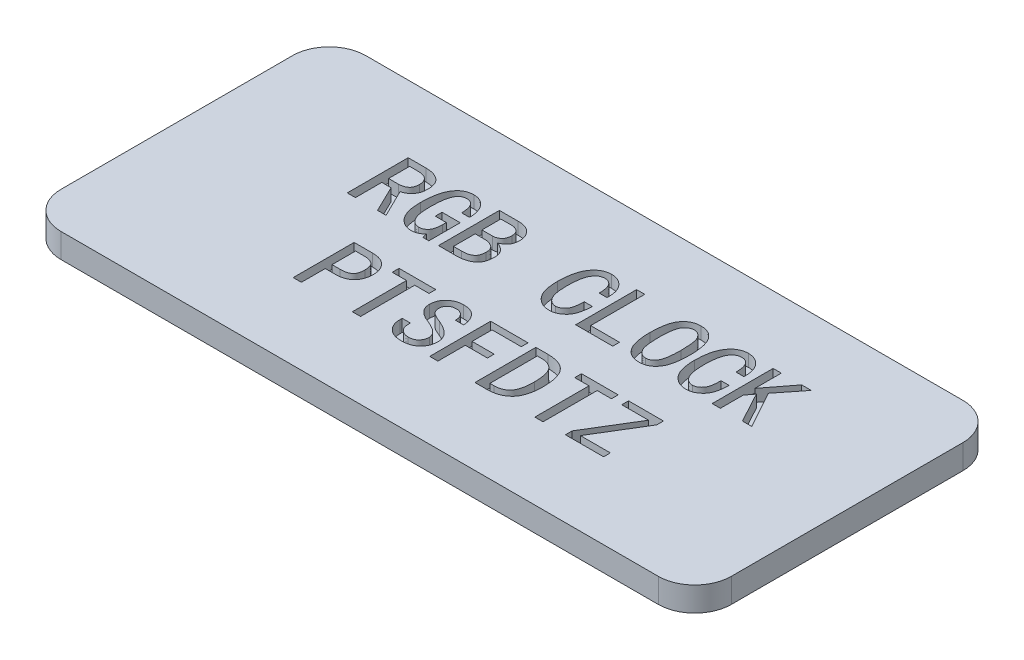
from build123d import *

# Parameters (mm, degrees)
EXTRUDE_1_DEPTH     = 4
CUT_EXTRUDE_1_DEPTH = 2
SKETCH_3_R          = 1.55
CUT_EXTRUDE_2_DEPTH = 2


with BuildPart() as part:
    # 草图1 → 凸台-拉伸1 (new body)
    with BuildSketch(Plane(origin=(0, 0, 0), x_dir=(1, 0, 0), z_dir=(0, 1, 0))):
        with BuildLine():
            Line((-49.060103211, -24.953020455), (48.939896789, -24.953020455))
            ThreePointArc((48.939896789, -24.953020455), (53.182537476, -23.195661143), (54.939896789, -18.953020455))
            Line((54.939896789, -18.953020455), (54.939896789, 19.046979545))
            ThreePointArc((54.939896789, 19.046979545), (53.182537476, 23.289620232), (48.939896789, 25.046979545))
            Line((48.939896789, 25.046979545), (-49.060103211, 25.046979545))
            ThreePointArc((-49.060103211, 25.046979545), (-53.302743898, 23.289620232), (-55.060103211, 19.046979545))
            Line((-55.060103211, 19.046979545), (-55.060103211, -18.953020455))
            ThreePointArc((-55.060103211, -18.953020455), (-53.302743898, -23.195661143), (-49.060103211, -24.953020455))
        make_face()
    extrude(amount=EXTRUDE_1_DEPTH)

    # 草图2 → 切除-拉伸1 (cut)
    with BuildSketch(Plane(origin=(0, 4, 0), x_dir=(1, 0, 0), z_dir=(0, 1, 0))):
        with BuildLine():
            Line((-24.689103402, 4.013286342), (-26.092612174, 4.013286342))
            Line((-26.092612174, 4.013286342), (-28.197875332, 8.340771722))
            Line((-28.197875332, 8.340771722), (-29.718343168, 8.340771722))
            Line((-29.718343168, 8.340771722), (-29.718343168, 4.013286342))
            Line((-29.718343168, 4.013286342), (-31.063372408, 4.013286342))
            Line((-31.063372408, 4.013286342), (-31.063372408, 14.013286342))
            Line((-31.063372408, 14.013286342), (-28.139395799, 14.013286342))
            add(Edge.make_bspline(
                [(-28.139395799, 14.013286342), (-28.025271199, 14.011022447), (-27.801665177, 14.006586764), (-27.474158532, 13.977305773), (-27.163811789, 13.922480888), (-26.869993583, 13.848543864), (-26.591122472, 13.757128365), (-26.330664058, 13.638152685), (-26.084604122, 13.502366925), (-25.856059717, 13.34436888), (-25.649198765, 13.162867164), (-25.468095095, 12.953694485), (-25.317506234, 12.71659107), (-25.19224016, 12.453536513), (-25.098862257, 12.163974849), (-25.028759565, 11.848745919), (-24.988061601, 11.506955486), (-24.983731739, 11.269910871), (-24.981501063, 11.147789266)],
                knots=[0, 0, 0, 0, 0.000342385, 0.00067084, 0.000985262, 0.001286791, 0.001579252, 0.001864265, 0.00214448, 0.002421463, 0.002696123, 0.002967934, 0.003248509, 0.003536249, 0.00383967, 0.004159169, 0.004503848, 0.004870117, 0.004870117, 0.004870117, 0.004870117], degree=3))
            add(Edge.make_bspline(
                [(-24.981501063, 11.147789266), (-24.982879235, 11.053132412), (-24.985568475, 10.868427619), (-25.014691702, 10.599897587), (-25.059459648, 10.347780009), (-25.122091088, 10.111878008), (-25.20381367, 9.892229091), (-25.306953951, 9.68976788), (-25.425462329, 9.502309698), (-25.607220143, 9.280192442), (-25.858260009, 9.03978442), (-26.186011564, 8.801825154), (-26.537419989, 8.621484855), (-26.787121493, 8.551180459), (-26.911325624, 8.516210319)],
                knots=[0, 0, 0, 0, 0.000283866, 0.000553911, 0.00080924, 0.001051445, 0.001285172, 0.001510863, 0.001731967, 0.001949131, 0.002370371, 0.002770706, 0.003161063, 0.003547397, 0.003547397, 0.003547397, 0.003547397], degree=3))
            Line((-26.911325624, 8.516210319), (-24.689103402, 4.013286342))
        make_face()
        with BuildLine():
            add(Edge.make_bspline(
                [(-26.326530302, 11.147789266), (-26.328534479, 11.214250313), (-26.332444587, 11.343914494), (-26.352988156, 11.533501173), (-26.392896046, 11.711592998), (-26.445391927, 11.879642896), (-26.519630989, 12.033952382), (-26.602039127, 12.180903159), (-26.706758189, 12.313205167), (-26.822926271, 12.438010916), (-26.958258394, 12.548784835), (-27.112075487, 12.645663856), (-27.28592479, 12.724656185), (-27.478483614, 12.789349783), (-27.689174032, 12.841491619), (-27.91960733, 12.87741334), (-28.169289215, 12.899287418), (-28.342221339, 12.901189847), (-28.43179346, 12.902175231)],
                knots=[0, 0, 0, 0, 0.000199452, 0.000389127, 0.00057096, 0.000746305, 0.000915883, 0.001083793, 0.001250582, 0.001420644, 0.001594525, 0.001773602, 0.00196451, 0.002165881, 0.002382309, 0.00261483, 0.002864849, 0.0031335, 0.0031335, 0.0031335, 0.0031335], degree=3))
            Line((-28.43179346, 12.902175231), (-29.718343168, 12.902175231))
            Line((-29.718343168, 12.902175231), (-29.718343168, 9.451882834))
            Line((-29.718343168, 9.451882834), (-28.080916267, 9.451882834))
            add(Edge.make_bspline(
                [(-28.080916267, 9.451882834), (-27.967162713, 9.456192603), (-27.744517212, 9.464627952), (-27.422963771, 9.538637856), (-27.122727476, 9.656901993), (-26.892686197, 9.794736061), (-26.726225717, 9.931497522), (-26.619535608, 10.055327959), (-26.52747784, 10.194651609), (-26.454418562, 10.352823259), (-26.395491566, 10.526910596), (-26.355058864, 10.718817973), (-26.33161966, 10.927724938), (-26.328268216, 11.072641731), (-26.326530302, 11.147789266)],
                knots=[0, 0, 0, 0, 0.000340881, 0.000667194, 0.000984128, 0.001305807, 0.001467207, 0.001628375, 0.001794177, 0.001966635, 0.00214951, 0.002344502, 0.00255379, 0.002779211, 0.002779211, 0.002779211, 0.002779211], degree=3))
        make_face(mode=Mode.SUBTRACT)
        with BuildLine():
            Line((-17.554600478, 3.896327278), (-18.548752525, 3.896327278))
            Line((-18.548752525, 3.896327278), (-18.724191121, 4.715040728))
            add(Edge.make_bspline(
                [(-18.724191121, 4.715040728), (-18.767152967, 4.657138884), (-18.854665698, 4.539193568), (-19.026038271, 4.386135142), (-19.226536717, 4.24628958), (-19.457565649, 4.124634124), (-19.708424871, 4.023547891), (-19.97477921, 3.949068451), (-20.252606224, 3.905489663), (-20.441606207, 3.899401816), (-20.537056618, 3.896327278)],
                knots=[0, 0, 0, 0, 0.00021581, 0.000439602, 0.000685354, 0.000947938, 0.001221032, 0.001495342, 0.001775942, 0.002062244, 0.002062244, 0.002062244, 0.002062244], degree=3))
            add(Edge.make_bspline(
                [(-20.537056618, 3.896327278), (-20.638393329, 3.899391095), (-20.839657805, 3.90547613), (-21.13618719, 3.962600689), (-21.425231964, 4.051279527), (-21.704153682, 4.178397868), (-21.976875627, 4.337911454), (-22.238279392, 4.537458024), (-22.493912412, 4.769441759), (-22.740767076, 5.036015722), (-22.966273141, 5.344424008), (-23.164784586, 5.695546473), (-23.32799682, 6.092111115), (-23.464059213, 6.529062097), (-23.566434359, 7.010010435), (-23.641434184, 7.532375234), (-23.686945452, 8.098107577), (-23.692223493, 8.489410749), (-23.694951355, 8.691648915)],
                knots=[0, 0, 0, 0, 0.000303722, 0.000603221, 0.000902595, 0.001208939, 0.001520596, 0.001848515, 0.002193521, 0.002555286, 0.00293651, 0.003337069, 0.003762255, 0.004220553, 0.004708263, 0.005235722, 0.005802851, 0.006409495, 0.006409495, 0.006409495, 0.006409495], degree=3))
            add(Edge.make_bspline(
                [(-23.694951355, 8.691648915), (-23.692775035, 8.913359196), (-23.688560111, 9.342750131), (-23.64721628, 9.965234327), (-23.578680878, 10.543660505), (-23.484728573, 11.078660128), (-23.362347657, 11.569958556), (-23.210680663, 12.017543399), (-23.03499896, 12.423166267), (-22.827454191, 12.782962495), (-22.597994066, 13.100142258), (-22.348366649, 13.377015533), (-22.074672425, 13.607010018), (-21.78531097, 13.801514937), (-21.472128306, 13.950116449), (-21.138594106, 14.052909771), (-20.785784046, 14.118253452), (-20.543847628, 14.126187271), (-20.420097554, 14.130245407)],
                knots=[0, 0, 0, 0, 0.000665061, 0.001288037, 0.001870474, 0.002411743, 0.002916567, 0.0033878, 0.003828071, 0.004240448, 0.004631225, 0.005000707, 0.005355685, 0.005701099, 0.006044058, 0.006391368, 0.006745691, 0.007116694, 0.007116694, 0.007116694, 0.007116694], degree=3))
            add(Edge.make_bspline(
                [(-20.420097554, 14.130245407), (-20.31089217, 14.127663594), (-20.097162626, 14.122610641), (-19.786366853, 14.073459764), (-19.493509176, 13.995694028), (-19.219088008, 13.887269168), (-18.962659104, 13.747353038), (-18.72579707, 13.575140885), (-18.507153532, 13.371322521), (-18.309367476, 13.137789323), (-18.133200876, 12.879637721), (-17.975218896, 12.604203803), (-17.846062031, 12.30800801), (-17.74010364, 11.994015887), (-17.654617307, 11.662735271), (-17.59835451, 11.31172633), (-17.559219047, 10.943636818), (-17.5561611, 10.691613794), (-17.554600478, 10.562993945)],
                knots=[0, 0, 0, 0, 0.000327403, 0.000640772, 0.000941296, 0.001234902, 0.001523748, 0.001815319, 0.002111098, 0.002418382, 0.002731392, 0.003047592, 0.003369549, 0.003699002, 0.004040982, 0.004394563, 0.004764604, 0.005150288, 0.005150288, 0.005150288, 0.005150288], degree=3))
            Line((-17.554600478, 10.562993945), (-18.841150185, 10.562993945))
            add(Edge.make_bspline(
                [(-18.841150185, 10.562993945), (-18.842363108, 10.661930975), (-18.844720629, 10.85423176), (-18.863804287, 11.132682661), (-18.897198766, 11.391969265), (-18.93808892, 11.632983599), (-18.997993791, 11.853819189), (-19.065367542, 12.057291794), (-19.150825297, 12.239282085), (-19.246302474, 12.403821723), (-19.353749221, 12.549263379), (-19.474823059, 12.674131444), (-19.60470689, 12.780583427), (-19.745711067, 12.869918008), (-19.899633309, 12.936018558), (-20.064161926, 12.983347825), (-20.238343238, 13.015685969), (-20.358578166, 13.017967121), (-20.420097554, 13.019134295)],
                knots=[0, 0, 0, 0, 0.000296801, 0.000576882, 0.000836665, 0.001080952, 0.001309483, 0.001522504, 0.001723093, 0.001911427, 0.002092498, 0.002264056, 0.002431841, 0.002595306, 0.002763105, 0.002932392, 0.003108298, 0.003292604, 0.003292604, 0.003292604, 0.003292604], degree=3))
            add(Edge.make_bspline(
                [(-20.420097554, 13.019134295), (-20.496165279, 13.016475256), (-20.643973815, 13.01130843), (-20.858556196, 12.963471092), (-21.058133515, 12.888294549), (-21.244108224, 12.782016552), (-21.414089428, 12.644794379), (-21.565250849, 12.473769415), (-21.708667994, 12.278701694), (-21.830654541, 12.046958379), (-21.942976861, 11.783382142), (-22.033227521, 11.47812312), (-22.116843033, 11.134570334), (-22.178593872, 10.747554505), (-22.231981468, 10.321509925), (-22.263135649, 9.853622017), (-22.289623969, 9.345330453), (-22.290821078, 8.992031024), (-22.291442583, 8.80860798)],
                knots=[0, 0, 0, 0, 0.000227925, 0.000442886, 0.000656082, 0.000865627, 0.001082791, 0.001308181, 0.001548636, 0.001807405, 0.002091808, 0.002406946, 0.002761024, 0.003151993, 0.003581832, 0.00404879, 0.004558336, 0.005108515, 0.005108515, 0.005108515, 0.005108515], degree=3))
            add(Edge.make_bspline(
                [(-22.291442583, 8.80860798), (-22.290155165, 8.635285666), (-22.287680366, 8.302108701), (-22.258608598, 7.823795567), (-22.215470736, 7.386770889), (-22.149669982, 6.993019323), (-22.07279778, 6.639037643), (-21.970334675, 6.328439459), (-21.853553436, 6.057481419), (-21.714391982, 5.828599149), (-21.563744754, 5.635958998), (-21.408798862, 5.469021681), (-21.248920538, 5.327437881), (-21.082454741, 5.211380418), (-20.91122122, 5.117991053), (-20.731516153, 5.056470315), (-20.548356839, 5.014666672), (-20.423937094, 5.009850635), (-20.361618022, 5.007438389)],
                knots=[0, 0, 0, 0, 0.00051989, 0.000999383, 0.001437101, 0.001836615, 0.002196528, 0.002522553, 0.002816359, 0.00307972, 0.003323632, 0.003548897, 0.003762225, 0.003962908, 0.004156693, 0.004345078, 0.004531144, 0.004717865, 0.004717865, 0.004717865, 0.004717865], degree=3))
            add(Edge.make_bspline(
                [(-20.361618022, 5.007438389), (-20.300158704, 5.009046757), (-20.179558496, 5.012202821), (-20.003759679, 5.038580972), (-19.837428873, 5.082083371), (-19.680867947, 5.142563078), (-19.534641443, 5.221122415), (-19.399242701, 5.31709912), (-19.275148506, 5.431456974), (-19.159348015, 5.561994511), (-19.055468567, 5.711367649), (-18.965990888, 5.880988719), (-18.890810411, 6.069064205), (-18.830674499, 6.276756235), (-18.783288112, 6.502688278), (-18.749611337, 6.747306991), (-18.726881054, 7.011199123), (-18.725110263, 7.193510252), (-18.724191121, 7.288140143)],
                knots=[0, 0, 0, 0, 0.000184306, 0.000361659, 0.000531873, 0.000699195, 0.000863933, 0.001028599, 0.001195711, 0.001369105, 0.001551158, 0.001740101, 0.001943212, 0.002157725, 0.002387964, 0.002635153, 0.002898121, 0.00318193, 0.00318193, 0.00318193, 0.00318193], degree=3))
            Line((-18.724191121, 7.288140143), (-18.724191121, 7.931414997))
            Line((-18.724191121, 7.931414997), (-20.537056618, 7.931414997))
            Line((-20.537056618, 7.931414997), (-20.537056618, 9.042526108))
            Line((-20.537056618, 9.042526108), (-17.554600478, 9.042526108))
            Line((-17.554600478, 9.042526108), (-17.554600478, 3.896327278))
        make_face()
        with BuildLine():
            add(Edge.make_bspline(
                [(-9.835302232, 6.995742483), (-9.838194545, 6.85989788), (-9.843764271, 6.598301901), (-9.886592254, 6.221845414), (-9.959392997, 5.878528129), (-10.060927464, 5.566871403), (-10.192620119, 5.288245647), (-10.354225391, 5.041581354), (-10.546643994, 4.829109441), (-10.768818301, 4.650863131), (-11.012354988, 4.500979148), (-11.271908085, 4.370041181), (-11.548147256, 4.259756781), (-11.840570881, 4.168605671), (-12.150073724, 4.099813668), (-12.475002148, 4.050625702), (-12.816438977, 4.019585569), (-13.04944295, 4.015418167), (-13.168635566, 4.013286342)],
                knots=[0, 0, 0, 0, 0.000407473, 0.000784671, 0.001134718, 0.001458686, 0.001765795, 0.002056543, 0.002340211, 0.002621988, 0.002908052, 0.003196703, 0.003493124, 0.003799346, 0.004114617, 0.004443301, 0.004784698, 0.005142237, 0.005142237, 0.005142237, 0.005142237], degree=3))
            Line((-13.168635566, 4.013286342), (-16.092612174, 4.013286342))
            Line((-16.092612174, 4.013286342), (-16.092612174, 14.013286342))
            Line((-16.092612174, 14.013286342), (-13.051676501, 14.013286342))
            add(Edge.make_bspline(
                [(-13.051676501, 14.013286342), (-12.93386989, 14.011787269), (-12.70485588, 14.008873096), (-12.372790656, 13.969705744), (-12.061747202, 13.914150165), (-11.775034516, 13.828427511), (-11.51073713, 13.723106537), (-11.269415541, 13.592361509), (-11.052481177, 13.435089961), (-10.856970566, 13.257760495), (-10.687635158, 13.061853055), (-10.536590849, 12.85864962), (-10.410401534, 12.644173901), (-10.305496411, 12.422138397), (-10.228154288, 12.188849476), (-10.168536596, 11.948038315), (-10.133458665, 11.696798894), (-10.129630325, 11.526207356), (-10.127699893, 11.440186927)],
                knots=[0, 0, 0, 0, 0.000353209, 0.000686632, 0.00100183, 0.001299947, 0.001582696, 0.001854083, 0.002120974, 0.002384682, 0.002644058, 0.002896616, 0.003143264, 0.003389387, 0.003631853, 0.003879279, 0.004132903, 0.004390874, 0.004390874, 0.004390874, 0.004390874], degree=3))
            add(Edge.make_bspline(
                [(-10.127699893, 11.440186927), (-10.129721519, 11.355689627), (-10.133650541, 11.191469402), (-10.153593265, 10.953642681), (-10.193768185, 10.73304651), (-10.245549209, 10.528952583), (-10.319435838, 10.343823652), (-10.401599595, 10.173101795), (-10.505561269, 10.022151827), (-10.65921891, 9.847786058), (-10.866689042, 9.663067585), (-11.119538263, 9.472046624), (-11.378852299, 9.321025488), (-11.559776513, 9.251789978), (-11.648167729, 9.217964705)],
                knots=[0, 0, 0, 0, 0.000253559, 0.000492792, 0.000714995, 0.000925668, 0.001123158, 0.00131204, 0.001492864, 0.001670943, 0.002008228, 0.00232402, 0.002620876, 0.002904444, 0.002904444, 0.002904444, 0.002904444], degree=3))
            add(Edge.make_bspline(
                [(-11.648167729, 9.217964705), (-11.532720987, 9.184783362), (-11.301593202, 9.118353335), (-10.977244338, 8.951804406), (-10.668433447, 8.745472829), (-10.432745001, 8.533986822), (-10.259574641, 8.343794331), (-10.146324647, 8.185724437), (-10.048202855, 8.017418993), (-9.970006563, 7.83535827), (-9.909597457, 7.642205313), (-9.866371104, 7.436987839), (-9.840036599, 7.220241436), (-9.836902482, 7.071624708), (-9.835302232, 6.995742483)],
                knots=[0, 0, 0, 0, 0.0003596, 0.000719929, 0.001088172, 0.001471654, 0.001666453, 0.001858817, 0.002053857, 0.002249809, 0.002451889, 0.002660042, 0.002878187, 0.003105772, 0.003105772, 0.003105772, 0.003105772], degree=3))
        make_face()
        with BuildLine():
            add(Edge.make_bspline(
                [(-11.472729133, 11.440186927), (-11.473677168, 11.501631584), (-11.475512798, 11.620603508), (-11.498094943, 11.792301519), (-11.532056634, 11.951289247), (-11.579856698, 12.097230079), (-11.63992816, 12.231317642), (-11.717568897, 12.35084035), (-11.805222728, 12.46105631), (-11.946242633, 12.583157261), (-12.140661178, 12.713110476), (-12.401991068, 12.824317478), (-12.68954145, 12.890989217), (-12.889585401, 12.898358405), (-12.993196969, 12.902175231)],
                knots=[0, 0, 0, 0, 0.000184217, 0.000356689, 0.000518554, 0.000671292, 0.000816667, 0.000957867, 0.001097916, 0.001237495, 0.001515627, 0.001796043, 0.002085011, 0.002395492, 0.002395492, 0.002395492, 0.002395492], degree=3))
            Line((-12.993196969, 12.902175231), (-14.747582934, 12.902175231))
            Line((-14.747582934, 12.902175231), (-14.747582934, 9.802760026))
            Line((-14.747582934, 9.802760026), (-13.051676501, 9.802760026))
            add(Edge.make_bspline(
                [(-13.051676501, 9.802760026), (-12.947993866, 9.807099138), (-12.744545963, 9.81561342), (-12.451512586, 9.889667278), (-12.179539995, 10.007799289), (-11.97413085, 10.146863385), (-11.827853574, 10.283209789), (-11.730520384, 10.401969028), (-11.650566723, 10.537443567), (-11.586056673, 10.68853639), (-11.533287766, 10.854413106), (-11.497836352, 11.036077892), (-11.47549494, 11.23314114), (-11.473675165, 11.369367813), (-11.472729133, 11.440186927)],
                knots=[0, 0, 0, 0, 0.00031064, 0.000609543, 0.000900493, 0.001196661, 0.001348352, 0.001499221, 0.001655602, 0.001818564, 0.001991186, 0.002176811, 0.002372942, 0.002585301, 0.002585301, 0.002585301, 0.002585301], degree=3))
        make_face(mode=Mode.SUBTRACT)
        with BuildLine():
            add(Edge.make_bspline(
                [(-11.238811004, 6.995742483), (-11.239912085, 7.070960781), (-11.242039541, 7.21629395), (-11.274164847, 7.425014661), (-11.320306295, 7.617376115), (-11.387923964, 7.792178904), (-11.474054047, 7.949999324), (-11.582943139, 8.087393825), (-11.706764682, 8.211790304), (-11.901927063, 8.346576266), (-12.165895596, 8.484288247), (-12.503264065, 8.604875771), (-12.859343395, 8.67847292), (-13.103309137, 8.687213374), (-13.227115098, 8.691648915)],
                knots=[0, 0, 0, 0, 0.000225421, 0.000435548, 0.000632014, 0.00081784, 0.000996236, 0.001169102, 0.001342171, 0.001520685, 0.001878191, 0.002232375, 0.002592581, 0.002963716, 0.002963716, 0.002963716, 0.002963716], degree=3))
            Line((-13.227115098, 8.691648915), (-14.747582934, 8.691648915))
            Line((-14.747582934, 8.691648915), (-14.747582934, 5.124397453))
            Line((-14.747582934, 5.124397453), (-13.402553694, 5.124397453))
            add(Edge.make_bspline(
                [(-13.402553694, 5.124397453), (-13.317329578, 5.12560666), (-13.151699907, 5.127956704), (-12.911441627, 5.147132179), (-12.686848796, 5.180718894), (-12.476626722, 5.221334944), (-12.283491118, 5.281859176), (-12.104060745, 5.348688208), (-11.943485361, 5.435946527), (-11.793747762, 5.529362382), (-11.661921211, 5.64367801), (-11.547887431, 5.778341519), (-11.450612186, 5.931978316), (-11.372018686, 6.106373076), (-11.311772384, 6.300656978), (-11.26971215, 6.51486888), (-11.243160195, 6.748887573), (-11.240300593, 6.911195192), (-11.238811004, 6.995742483)],
                knots=[0, 0, 0, 0, 0.00025566, 0.000496865, 0.000722306, 0.000936819, 0.00113826, 0.001328909, 0.001510083, 0.001685509, 0.001857477, 0.002031088, 0.002213153, 0.002401188, 0.002603269, 0.002822025, 0.00305523, 0.00330879, 0.00330879, 0.00330879, 0.00330879], degree=3))
        make_face(mode=Mode.SUBTRACT)
        with BuildLine():
            add(Edge.make_bspline(
                [(5.193937534, 7.989894529), (5.186438907, 7.811448015), (5.171959697, 7.466882999), (5.120498776, 6.9705436), (5.043781807, 6.514347834), (4.940446892, 6.098291311), (4.811120762, 5.72153954), (4.656056989, 5.383689447), (4.473924981, 5.086519007), (4.265937862, 4.830449595), (4.038311786, 4.612583624), (3.802711299, 4.419821618), (3.554085419, 4.259838711), (3.296556983, 4.124255767), (3.025088993, 4.024223909), (2.74400416, 3.949181454), (2.451825675, 3.90538099), (2.2534984, 3.899372105), (2.153001861, 3.896327278)],
                knots=[0, 0, 0, 0, 0.00053572, 0.001034429, 0.001495905, 0.001922457, 0.002319055, 0.002689223, 0.003035443, 0.003361871, 0.003675868, 0.003979288, 0.004273661, 0.004561368, 0.004850612, 0.005139556, 0.005433003, 0.005734446, 0.005734446, 0.005734446, 0.005734446], degree=3))
            add(Edge.make_bspline(
                [(2.153001861, 3.896327278), (2.037975229, 3.899344221), (1.810936407, 3.905299043), (1.47768681, 3.962049492), (1.156127946, 4.050306928), (0.848810871, 4.17718289), (0.552144418, 4.33650667), (0.270919407, 4.534494), (0.003765836, 4.769431276), (-0.254028755, 5.03497626), (-0.488915245, 5.342875043), (-0.690450367, 5.696004161), (-0.86242027, 6.090829452), (-0.998228535, 6.529437718), (-1.106984084, 7.009527858), (-1.182784795, 7.53237258), (-1.231497194, 8.097986922), (-1.236319208, 8.489389838), (-1.238811004, 8.691648915)],
                knots=[0, 0, 0, 0, 0.000344815, 0.000680594, 0.001011134, 0.00134336, 0.001675768, 0.002019466, 0.002372569, 0.002741747, 0.003128154, 0.003530861, 0.003958605, 0.004417553, 0.004906204, 0.00543398, 0.006001286, 0.00660793, 0.00660793, 0.00660793, 0.00660793], degree=3))
            add(Edge.make_bspline(
                [(-1.238811004, 8.691648915), (-1.23607727, 8.913372014), (-1.23078173, 9.342873845), (-1.185148542, 9.965526019), (-1.109858917, 10.544003184), (-1.008350414, 11.079756566), (-0.87106408, 11.570284924), (-0.708486335, 12.019849563), (-0.511198058, 12.423974946), (-0.28497315, 12.784771452), (-0.033200869, 13.099688758), (0.23341388, 13.377227808), (0.522264616, 13.606800332), (0.824452623, 13.801373838), (1.147128022, 13.948848652), (1.487139584, 14.053415767), (1.843737422, 14.11774088), (2.087756942, 14.126038361), (2.211481393, 14.130245407)],
                knots=[0, 0, 0, 0, 0.000665107, 0.001288384, 0.001871629, 0.002414491, 0.002922649, 0.003398223, 0.003846712, 0.004269153, 0.004673036, 0.005054414, 0.005421087, 0.00577741, 0.00613018, 0.006481625, 0.006842345, 0.007213348, 0.007213348, 0.007213348, 0.007213348], degree=3))
            add(Edge.make_bspline(
                [(2.211481393, 14.130245407), (2.316333332, 14.127427815), (2.522720891, 14.121881749), (2.825577419, 14.075164097), (3.114299402, 13.999208767), (3.390575344, 13.895283597), (3.651517099, 13.757180092), (3.898850736, 13.589812413), (4.132978686, 13.392766755), (4.350302156, 13.166485793), (4.547510694, 12.912795459), (4.72061961, 12.634400922), (4.86051848, 12.328816187), (4.973737524, 11.99947945), (5.057388796, 11.645336434), (5.112868122, 11.267123111), (5.141649037, 10.86449439), (5.137562792, 10.588300205), (5.135458002, 10.44603488)],
                knots=[0, 0, 0, 0, 0.000314422, 0.0006189, 0.000916774, 0.00120881, 0.001502361, 0.001800321, 0.002103153, 0.002418708, 0.002739745, 0.003065532, 0.003399848, 0.003745749, 0.004108757, 0.00448981, 0.004891491, 0.005318175, 0.005318175, 0.005318175, 0.005318175], degree=3))
            Line((5.135458002, 10.44603488), (3.848908294, 10.44603488))
            add(Edge.make_bspline(
                [(3.848908294, 10.44603488), (3.847740787, 10.550027536), (3.845484638, 10.750988115), (3.825915524, 11.043091219), (3.793131163, 11.314703168), (3.752240805, 11.567267755), (3.691541572, 11.79797433), (3.62517174, 12.011072207), (3.539071659, 12.202177043), (3.44436999, 12.375057639), (3.336243847, 12.527847448), (3.2135416, 12.659356714), (3.078138605, 12.770829981), (2.930012106, 12.863049492), (2.767541104, 12.932351912), (2.593575928, 12.981731789), (2.406805554, 13.013080685), (2.278031786, 13.017071723), (2.211481393, 13.019134295)],
                knots=[0, 0, 0, 0, 0.000311959, 0.000602844, 0.000877676, 0.001132628, 0.001369545, 0.001592833, 0.001801313, 0.001997169, 0.002183487, 0.00236125, 0.002535131, 0.002708241, 0.002882862, 0.003063154, 0.003249737, 0.003449294, 0.003449294, 0.003449294, 0.003449294], degree=3))
            add(Edge.make_bspline(
                [(2.211481393, 13.019134295), (2.135450492, 13.016297216), (1.985593661, 13.010705336), (1.767141619, 12.9640811), (1.561388875, 12.88682786), (1.365590633, 12.782153308), (1.183186623, 12.644002886), (1.01397119, 12.47558078), (0.85670525, 12.277712608), (0.710962243, 12.049059075), (0.580491093, 11.784295885), (0.46814977, 11.480106258), (0.374351641, 11.134895527), (0.297272284, 10.748379205), (0.237697311, 10.321647655), (0.195111679, 9.854015214), (0.169202318, 9.345325705), (0.166237107, 8.99202049), (0.164697768, 8.80860798)],
                knots=[0, 0, 0, 0, 0.000227925, 0.00044924, 0.000666491, 0.000885505, 0.001112925, 0.001350317, 0.001599952, 0.001869727, 0.002162253, 0.002483691, 0.002841014, 0.003234351, 0.003665324, 0.004133004, 0.004642656, 0.005192865, 0.005192865, 0.005192865, 0.005192865], degree=3))
            add(Edge.make_bspline(
                [(0.164697768, 8.80860798), (0.166235961, 8.639632505), (0.169196006, 8.314461967), (0.195044452, 7.846877412), (0.237718589, 7.418196913), (0.296900943, 7.02884105), (0.374617593, 6.677726436), (0.468147718, 6.365494141), (0.580172315, 6.091939507), (0.711224445, 5.856764754), (0.857967964, 5.656994713), (1.012303983, 5.483197694), (1.177702955, 5.337449261), (1.35232219, 5.216235714), (1.538203001, 5.122283656), (1.734021367, 5.054618057), (1.940561626, 5.014622797), (2.081351955, 5.009861481), (2.153001861, 5.007438389)],
                knots=[0, 0, 0, 0, 0.000506897, 0.000975454, 0.001404332, 0.001798884, 0.002156206, 0.002482332, 0.002775563, 0.003041264, 0.003287769, 0.003517825, 0.003737267, 0.003947538, 0.004153857, 0.004360029, 0.004567323, 0.004782142, 0.004782142, 0.004782142, 0.004782142], degree=3))
            add(Edge.make_bspline(
                [(2.153001861, 5.007438389), (2.205868793, 5.008730468), (2.311775463, 5.011318848), (2.467793217, 5.044041626), (2.621271982, 5.091618585), (2.770916567, 5.158429629), (2.91434546, 5.247653256), (3.057130305, 5.350941364), (3.191739295, 5.479061597), (3.329426391, 5.620935827), (3.455342762, 5.794724438), (3.559355959, 6.005704027), (3.650967883, 6.249997066), (3.721893618, 6.53001939), (3.781173091, 6.844521413), (3.820532492, 7.194884178), (3.843902611, 7.580936654), (3.847193479, 7.849796359), (3.848908294, 7.989894529)],
                knots=[0, 0, 0, 0, 0.000158349, 0.000317215, 0.00047614, 0.000639978, 0.000807132, 0.000982142, 0.001167615, 0.001363747, 0.001574742, 0.001808188, 0.002067266, 0.00235621, 0.002673536, 0.003026818, 0.003413085, 0.003833361, 0.003833361, 0.003833361, 0.003833361], degree=3))
            Line((3.848908294, 7.989894529), (5.193937534, 7.989894529))
        make_face()
        Polygon((12.503879054, 4.013286342), (6.422007709, 4.013286342), (6.422007709, 14.013286342), (7.767036949, 14.013286342), (7.767036949, 5.124397453), (12.503879054, 5.124397453), align=None)
        with BuildLine():
            add(Edge.make_bspline(
                [(20.106218236, 9.042526108), (20.10384304, 8.82154901), (20.099259416, 8.395110033), (20.061048368, 7.779780823), (19.994477885, 7.212863647), (19.902582689, 6.693878072), (19.784794416, 6.222812423), (19.640839808, 5.799192567), (19.4678618, 5.424148305), (19.267623492, 5.095671733), (19.042546241, 4.812214536), (18.798322874, 4.566381125), (18.53203891, 4.358852053), (18.244793783, 4.188610525), (17.93570772, 4.057658943), (17.606089479, 3.964878524), (17.255004493, 3.907253143), (17.013526559, 3.90002795), (16.889843967, 3.896327278)],
                knots=[0, 0, 0, 0, 0.000662895, 0.001279248, 0.001848523, 0.002374487, 0.002859351, 0.00330389, 0.003714751, 0.004095877, 0.004455111, 0.004798173, 0.005133078, 0.005465162, 0.005797055, 0.00613711, 0.006490339, 0.006861222, 0.006861222, 0.006861222, 0.006861222], degree=3))
            add(Edge.make_bspline(
                [(16.889843967, 3.896327278), (16.766155688, 3.899999817), (16.524666653, 3.907170084), (16.172286058, 3.965414788), (15.83980734, 4.057727141), (15.526651837, 4.187873455), (15.236359967, 4.360063352), (14.964119697, 4.566009882), (14.713408714, 4.81196369), (14.481949156, 5.095379902), (14.274516612, 5.423197336), (14.09828434, 5.799472316), (13.946495967, 6.222081128), (13.824711572, 6.693548317), (13.731072746, 7.212805713), (13.662340053, 7.779711108), (13.621340526, 8.395032095), (13.617157524, 8.821538428), (13.614990165, 9.042526108)],
                knots=[0, 0, 0, 0, 0.000370883, 0.000724112, 0.001068335, 0.001404218, 0.001738169, 0.002078223, 0.002425911, 0.002789216, 0.003173779, 0.003586485, 0.004033188, 0.004519134, 0.005045485, 0.005615021, 0.006231514, 0.006894409, 0.006894409, 0.006894409, 0.006894409], degree=3))
            add(Edge.make_bspline(
                [(13.614990165, 9.042526108), (13.617146032, 9.263513625), (13.621299826, 9.689299215), (13.662297721, 10.303189515), (13.731177286, 10.867899329), (13.824066418, 11.383740682), (13.946815011, 11.850700215), (14.098433184, 12.268222264), (14.273260527, 12.639712374), (14.482784779, 12.959798613), (14.713316927, 13.236709257), (14.96499667, 13.475795774), (15.236366725, 13.677735254), (15.527398956, 13.844836763), (15.839828284, 13.973518797), (16.172655095, 14.062581596), (16.524558083, 14.122282408), (16.766130488, 14.127548532), (16.889843967, 14.130245407)],
                knots=[0, 0, 0, 0, 0.000662895, 0.001277227, 0.001844613, 0.002368834, 0.002848499, 0.003291129, 0.00369993, 0.004077202, 0.004435495, 0.00477868, 0.005116131, 0.005447911, 0.005782963, 0.006126606, 0.006479835, 0.00685061, 0.00685061, 0.00685061, 0.00685061], degree=3))
            add(Edge.make_bspline(
                [(16.889843967, 14.130245407), (17.013552165, 14.127521393), (17.255114259, 14.122202277), (17.605714604, 14.063113091), (17.935683784, 13.973584715), (18.244054599, 13.844113575), (18.532005914, 13.678934557), (18.797453074, 13.475451154), (19.042643281, 13.236454407), (19.26680431, 12.959528272), (19.469117469, 12.638721599), (19.640688929, 12.268508545), (19.784493379, 11.849968695), (19.90321192, 11.383400046), (19.994376882, 10.867842736), (20.061089034, 10.303118984), (20.099298052, 9.689221026), (20.103853596, 9.263503001), (20.106218236, 9.042526108)],
                knots=[0, 0, 0, 0, 0.000370775, 0.000724005, 0.001063472, 0.001394523, 0.001724425, 0.002056685, 0.002395184, 0.002749349, 0.003123117, 0.003530054, 0.003970501, 0.004449069, 0.004972901, 0.005540026, 0.006154217, 0.006817112, 0.006817112, 0.006817112, 0.006817112], degree=3))
        make_face()
        with BuildLine():
            add(Edge.make_bspline(
                [(18.702709464, 9.042526108), (18.700990675, 9.238204395), (18.697703932, 9.612388855), (18.674665679, 10.147054156), (18.634857545, 10.629245746), (18.576613991, 11.05859208), (18.505699833, 11.43637762), (18.415355164, 11.760392216), (18.311839283, 12.033327693), (18.185792324, 12.254596786), (18.046676855, 12.435510122), (17.905207663, 12.59208637), (17.754316375, 12.724315577), (17.594815406, 12.830306373), (17.430242769, 12.917149487), (17.255900966, 12.97473458), (17.075731566, 13.014255518), (16.952149361, 13.017499038), (16.889843967, 13.019134295)],
                knots=[0, 0, 0, 0, 0.000587025, 0.001122535, 0.001605124, 0.002037943, 0.002421939, 0.002757235, 0.003046016, 0.003295322, 0.003517979, 0.00372953, 0.003927577, 0.004118005, 0.004303022, 0.004483846, 0.004667349, 0.004853931, 0.004853931, 0.004853931, 0.004853931], degree=3))
            add(Edge.make_bspline(
                [(16.889843967, 13.019134295), (16.827544728, 13.017456159), (16.703266082, 13.014108501), (16.521662519, 12.974723578), (16.345147146, 12.917229582), (16.177964862, 12.829893724), (16.014519684, 12.723794132), (15.857049037, 12.593235908), (15.711708327, 12.434227604), (15.563067355, 12.256019626), (15.431154243, 12.033690242), (15.320146307, 11.761244346), (15.226449768, 11.436499845), (15.150262746, 11.058967181), (15.090779191, 10.629265188), (15.04864821, 10.14711815), (15.022895964, 9.61244164), (15.02000869, 9.23821099), (15.018498937, 9.042526108)],
                knots=[0, 0, 0, 0, 0.000186583, 0.000372207, 0.000555083, 0.000742029, 0.000936069, 0.001139064, 0.001353566, 0.001581553, 0.001834139, 0.002125371, 0.002461868, 0.002846718, 0.003279835, 0.003762614, 0.004298224, 0.004885249, 0.004885249, 0.004885249, 0.004885249], degree=3))
            add(Edge.make_bspline(
                [(15.018498937, 9.042526108), (15.020023698, 8.846842045), (15.022945293, 8.471891803), (15.048613211, 7.935766636), (15.090988558, 7.450765967), (15.150060986, 7.018135792), (15.2266219, 6.637042996), (15.32116741, 6.30770129), (15.430642639, 6.028258769), (15.563267666, 5.799192427), (15.710910984, 5.614184596), (15.857769823, 5.451018139), (16.013721105, 5.313789569), (16.177355901, 5.203079045), (16.345105665, 5.114040396), (16.521231551, 5.053316826), (16.703396568, 5.015347888), (16.827572984, 5.010080058), (16.889843967, 5.007438389)],
                knots=[0, 0, 0, 0, 0.000587025, 0.001124799, 0.001609735, 0.002047141, 0.002434112, 0.002774767, 0.003074007, 0.003332187, 0.003565271, 0.003782942, 0.003990157, 0.004186599, 0.004374535, 0.004558114, 0.004743739, 0.00493046, 0.00493046, 0.00493046, 0.00493046], degree=3))
            add(Edge.make_bspline(
                [(16.889843967, 5.007438389), (16.952120579, 5.010038891), (17.075600352, 5.015195071), (17.256336482, 5.053311169), (17.430282376, 5.114122525), (17.595442596, 5.202667573), (17.75514097, 5.313294706), (17.904444319, 5.452140933), (18.047508077, 5.612944063), (18.185549011, 5.800592989), (18.312331081, 6.028629874), (18.414362244, 6.308504831), (18.505535331, 6.637164435), (18.576805807, 7.018509998), (18.634655775, 7.45078369), (18.674700333, 7.935830487), (18.697657625, 8.471944243), (18.700976967, 8.846848559), (18.702709464, 9.042526108)],
                knots=[0, 0, 0, 0, 0.000186721, 0.000370223, 0.00055176, 0.000737776, 0.000930651, 0.001133022, 0.001347785, 0.001575659, 0.00183063, 0.002127486, 0.002466954, 0.002853075, 0.003290186, 0.003774934, 0.004312607, 0.004899632, 0.004899632, 0.004899632, 0.004899632], degree=3))
        make_face(mode=Mode.SUBTRACT)
        with BuildLine():
            add(Edge.make_bspline(
                [(27.650077885, 7.989894529), (27.642579258, 7.811448015), (27.628100048, 7.466882999), (27.576639127, 6.9705436), (27.499922158, 6.514347834), (27.396587243, 6.098291311), (27.267261113, 5.72153954), (27.11219734, 5.383689447), (26.930065332, 5.086519007), (26.722078213, 4.830449595), (26.494452137, 4.612583624), (26.258851649, 4.419821618), (26.01022577, 4.259838711), (25.752697333, 4.124255767), (25.481229344, 4.024223909), (25.200144511, 3.949181454), (24.907966026, 3.90538099), (24.709638751, 3.899372105), (24.609142212, 3.896327278)],
                knots=[0, 0, 0, 0, 0.00053572, 0.001034429, 0.001495905, 0.001922457, 0.002319055, 0.002689223, 0.003035443, 0.003361871, 0.003675868, 0.003979288, 0.004273661, 0.004561368, 0.004850612, 0.005139556, 0.005433003, 0.005734446, 0.005734446, 0.005734446, 0.005734446], degree=3))
            add(Edge.make_bspline(
                [(24.609142212, 3.896327278), (24.49411558, 3.899344221), (24.267076758, 3.905299043), (23.933827161, 3.962049492), (23.612268297, 4.050306928), (23.304951222, 4.17718289), (23.008284769, 4.33650667), (22.727059758, 4.534494), (22.459906187, 4.769431276), (22.202111596, 5.03497626), (21.967225106, 5.342875043), (21.765689984, 5.696004161), (21.593720081, 6.090829452), (21.457911816, 6.529437718), (21.349156267, 7.009527858), (21.273355556, 7.53237258), (21.224643156, 8.097986922), (21.219821142, 8.489389838), (21.217329347, 8.691648915)],
                knots=[0, 0, 0, 0, 0.000344815, 0.000680594, 0.001011134, 0.00134336, 0.001675768, 0.002019466, 0.002372569, 0.002741747, 0.003128154, 0.003530861, 0.003958605, 0.004417553, 0.004906204, 0.00543398, 0.006001286, 0.00660793, 0.00660793, 0.00660793, 0.00660793], degree=3))
            add(Edge.make_bspline(
                [(21.217329347, 8.691648915), (21.220063081, 8.913372014), (21.225358621, 9.342873845), (21.270991809, 9.965526019), (21.346281434, 10.544003184), (21.447789937, 11.079756566), (21.585076271, 11.570284924), (21.747654016, 12.019849563), (21.944942293, 12.423974946), (22.171167201, 12.784771452), (22.422939482, 13.099688758), (22.689554231, 13.377227808), (22.978404967, 13.606800332), (23.280592974, 13.801373838), (23.603268373, 13.948848652), (23.943279935, 14.053415767), (24.299877773, 14.11774088), (24.543897293, 14.126038361), (24.667621744, 14.130245407)],
                knots=[0, 0, 0, 0, 0.000665107, 0.001288384, 0.001871629, 0.002414491, 0.002922649, 0.003398223, 0.003846712, 0.004269153, 0.004673036, 0.005054414, 0.005421087, 0.00577741, 0.00613018, 0.006481625, 0.006842345, 0.007213348, 0.007213348, 0.007213348, 0.007213348], degree=3))
            add(Edge.make_bspline(
                [(24.667621744, 14.130245407), (24.772473683, 14.127427815), (24.978861242, 14.121881749), (25.28171777, 14.075164097), (25.570439752, 13.999208767), (25.846715695, 13.895283597), (26.10765745, 13.757180092), (26.354991087, 13.589812413), (26.589119037, 13.392766755), (26.806442507, 13.166485793), (27.003651045, 12.912795459), (27.17675996, 12.634400922), (27.316658831, 12.328816187), (27.429877875, 11.99947945), (27.513529146, 11.645336434), (27.569008473, 11.267123111), (27.597789388, 10.86449439), (27.593703143, 10.588300205), (27.591598353, 10.44603488)],
                knots=[0, 0, 0, 0, 0.000314422, 0.0006189, 0.000916774, 0.00120881, 0.001502361, 0.001800321, 0.002103153, 0.002418708, 0.002739745, 0.003065532, 0.003399848, 0.003745749, 0.004108757, 0.00448981, 0.004891491, 0.005318175, 0.005318175, 0.005318175, 0.005318175], degree=3))
            Line((27.591598353, 10.44603488), (26.305048645, 10.44603488))
            add(Edge.make_bspline(
                [(26.305048645, 10.44603488), (26.303881138, 10.550027536), (26.301624989, 10.750988115), (26.282055875, 11.043091219), (26.249271513, 11.314703168), (26.208381156, 11.567267755), (26.147681923, 11.79797433), (26.081312091, 12.011072207), (25.99521201, 12.202177043), (25.900510341, 12.375057639), (25.792384198, 12.527847448), (25.669681951, 12.659356714), (25.534278956, 12.770829981), (25.386152457, 12.863049492), (25.223681455, 12.932351912), (25.049716279, 12.981731789), (24.862945905, 13.013080685), (24.734172137, 13.017071723), (24.667621744, 13.019134295)],
                knots=[0, 0, 0, 0, 0.000311959, 0.000602844, 0.000877676, 0.001132628, 0.001369545, 0.001592833, 0.001801313, 0.001997169, 0.002183487, 0.00236125, 0.002535131, 0.002708241, 0.002882862, 0.003063154, 0.003249737, 0.003449294, 0.003449294, 0.003449294, 0.003449294], degree=3))
            add(Edge.make_bspline(
                [(24.667621744, 13.019134295), (24.591590843, 13.016297216), (24.441734012, 13.010705336), (24.22328197, 12.9640811), (24.017529226, 12.88682786), (23.821730984, 12.782153308), (23.639326974, 12.644002886), (23.470111541, 12.47558078), (23.312845601, 12.277712608), (23.167102594, 12.049059075), (23.036631444, 11.784295885), (22.924290121, 11.480106258), (22.830491992, 11.134895527), (22.753412635, 10.748379205), (22.693837662, 10.321647655), (22.65125203, 9.854015214), (22.625342669, 9.345325705), (22.622377458, 8.99202049), (22.620838119, 8.80860798)],
                knots=[0, 0, 0, 0, 0.000227925, 0.00044924, 0.000666491, 0.000885505, 0.001112925, 0.001350317, 0.001599952, 0.001869727, 0.002162253, 0.002483691, 0.002841014, 0.003234351, 0.003665324, 0.004133004, 0.004642656, 0.005192865, 0.005192865, 0.005192865, 0.005192865], degree=3))
            add(Edge.make_bspline(
                [(22.620838119, 8.80860798), (22.622376312, 8.639632505), (22.625336357, 8.314461967), (22.651184803, 7.846877412), (22.69385894, 7.418196913), (22.753041294, 7.02884105), (22.830757943, 6.677726436), (22.924288069, 6.365494141), (23.036312666, 6.091939507), (23.167364796, 5.856764754), (23.314108314, 5.656994713), (23.468444334, 5.483197694), (23.633843306, 5.337449261), (23.808462541, 5.216235714), (23.994343352, 5.122283656), (24.190161718, 5.054618057), (24.396701977, 5.014622797), (24.537492306, 5.009861481), (24.609142212, 5.007438389)],
                knots=[0, 0, 0, 0, 0.000506897, 0.000975454, 0.001404332, 0.001798884, 0.002156206, 0.002482332, 0.002775563, 0.003041264, 0.003287769, 0.003517825, 0.003737267, 0.003947538, 0.004153857, 0.004360029, 0.004567323, 0.004782142, 0.004782142, 0.004782142, 0.004782142], degree=3))
            add(Edge.make_bspline(
                [(24.609142212, 5.007438389), (24.662009143, 5.008730468), (24.767915814, 5.011318848), (24.923933568, 5.044041626), (25.077412333, 5.091618585), (25.227056918, 5.158429629), (25.370485811, 5.247653256), (25.513270656, 5.350941364), (25.647879646, 5.479061597), (25.785566742, 5.620935827), (25.911483112, 5.794724438), (26.01549631, 6.005704027), (26.107108234, 6.249997066), (26.178033969, 6.53001939), (26.237313442, 6.844521413), (26.276672842, 7.194884178), (26.300042962, 7.580936654), (26.30333383, 7.849796359), (26.305048645, 7.989894529)],
                knots=[0, 0, 0, 0, 0.000158349, 0.000317215, 0.00047614, 0.000639978, 0.000807132, 0.000982142, 0.001167615, 0.001363747, 0.001574742, 0.001808188, 0.002067266, 0.00235621, 0.002673536, 0.003026818, 0.003413085, 0.003833361, 0.003833361, 0.003833361, 0.003833361], degree=3))
            Line((26.305048645, 7.989894529), (27.650077885, 7.989894529))
        make_face()
        Polygon((35.310896598, 4.013286342), (33.790428762, 4.013286342), (31.100370282, 8.984046576), (30.164697768, 7.755976401), (30.164697768, 4.013286342), (28.819668528, 4.013286342), (28.819668528, 14.013286342), (30.164697768, 14.013286342), (30.164697768, 9.685800962), (33.498031101, 14.013286342), (35.07697847, 14.013286342), (31.977563265, 10.095157687), align=None)
        with BuildLine():
            add(Edge.make_bspline(
                [(-17.320682349, -5.498409564), (-17.32296856, -5.612610933), (-17.327424865, -5.835213406), (-17.36816946, -6.159611128), (-17.42936502, -6.465972694), (-17.518777142, -6.755078049), (-17.6352034, -7.025121744), (-17.777773412, -7.276377791), (-17.942847144, -7.510999362), (-18.136200727, -7.72377731), (-18.349508623, -7.9185692), (-18.58829686, -8.08195868), (-18.843102974, -8.225450298), (-19.120751435, -8.339196453), (-19.416924655, -8.430997429), (-19.734409434, -8.492085792), (-20.070337627, -8.532558492), (-20.301568513, -8.537045298), (-20.420097554, -8.539345237)],
                knots=[0, 0, 0, 0, 0.00034246, 0.000667527, 0.000979312, 0.001278686, 0.001573608, 0.001859721, 0.002143984, 0.002432318, 0.002720652, 0.003008458, 0.00329835, 0.003596412, 0.003906773, 0.004227049, 0.004565021, 0.004920468, 0.004920468, 0.004920468, 0.004920468], degree=3))
            Line((-20.420097554, -8.539345237), (-22.116003987, -8.539345237))
            Line((-22.116003987, -8.539345237), (-22.116003987, -12.457473892))
            Line((-22.116003987, -12.457473892), (-23.461033226, -12.457473892))
            Line((-23.461033226, -12.457473892), (-23.461033226, -2.457473892))
            Line((-23.461033226, -2.457473892), (-20.420097554, -2.457473892))
            add(Edge.make_bspline(
                [(-20.420097554, -2.457473892), (-20.301576651, -2.459798652), (-20.070361638, -2.46433388), (-19.734320837, -2.504463079), (-19.417439518, -2.566724831), (-19.119783894, -2.65422392), (-18.84367971, -2.772068359), (-18.588209341, -2.914640629), (-18.349533533, -3.078309379), (-18.136188498, -3.273023593), (-17.94287096, -3.485833021), (-17.77769132, -3.720406717), (-17.63584109, -3.971247993), (-17.517792966, -4.24064639), (-17.429845867, -4.530286398), (-17.368071705, -4.837174895), (-17.327451282, -5.161614669), (-17.322977517, -5.384211229), (-17.320682349, -5.498409564)],
                knots=[0, 0, 0, 0, 0.000355447, 0.000693419, 0.001013695, 0.001323427, 0.001622331, 0.001912223, 0.002200028, 0.002488362, 0.002776697, 0.003060959, 0.003347073, 0.003640007, 0.00394145, 0.004253236, 0.004578302, 0.004920762, 0.004920762, 0.004920762, 0.004920762], degree=3))
        make_face()
        with BuildLine():
            add(Edge.make_bspline(
                [(-18.665711589, -5.498409564), (-18.667439659, -5.409553211), (-18.670761967, -5.238722069), (-18.694108869, -4.993132827), (-18.734282764, -4.768819936), (-18.793162459, -4.566661883), (-18.865032121, -4.384900832), (-18.958217484, -4.227308096), (-19.063251363, -4.088370582), (-19.190286222, -3.973910945), (-19.333730047, -3.879443038), (-19.489276308, -3.793587822), (-19.663760954, -3.725035017), (-19.85309864, -3.666018949), (-20.06023267, -3.624563084), (-20.282035968, -3.591379743), (-20.520833628, -3.572063865), (-20.685748261, -3.569770298), (-20.770974747, -3.568585003)],
                knots=[0, 0, 0, 0, 0.000266548, 0.000512452, 0.000739305, 0.000949051, 0.00114332, 0.001323859, 0.001496725, 0.001663837, 0.001833844, 0.002011197, 0.002195808, 0.002395178, 0.002605449, 0.002828748, 0.003067794, 0.003323454, 0.003323454, 0.003323454, 0.003323454], degree=3))
            Line((-20.770974747, -3.568585003), (-22.116003987, -3.568585003))
            Line((-22.116003987, -3.568585003), (-22.116003987, -7.428234126))
            Line((-22.116003987, -7.428234126), (-20.770974747, -7.428234126))
            add(Edge.make_bspline(
                [(-20.770974747, -7.428234126), (-20.685748261, -7.42704883), (-20.520833628, -7.424755264), (-20.282035968, -7.405439386), (-20.06023267, -7.372256044), (-19.85309864, -7.330800179), (-19.663760954, -7.271784111), (-19.489276308, -7.203231306), (-19.333730047, -7.11737609), (-19.190286222, -7.022908183), (-19.063251363, -6.908448547), (-18.958217484, -6.769511032), (-18.865032121, -6.611918296), (-18.793162459, -6.430157245), (-18.734282764, -6.227999192), (-18.694108869, -6.003686301), (-18.670761967, -5.758097059), (-18.667439659, -5.587265917), (-18.665711589, -5.498409564)],
                knots=[0, 0, 0, 0, 0.00025566, 0.000494706, 0.000718005, 0.000928276, 0.001127646, 0.001312257, 0.00148961, 0.001659617, 0.001826729, 0.001999595, 0.002180134, 0.002374403, 0.002584149, 0.002811002, 0.003056906, 0.003323454, 0.003323454, 0.003323454, 0.003323454], degree=3))
        make_face(mode=Mode.SUBTRACT)
        Polygon((-10.069220361, -3.568585003), (-12.408401647, -3.568585003), (-12.408401647, -12.457473892), (-13.753430887, -12.457473892), (-13.753430887, -3.568585003), (-16.092612174, -3.568585003), (-16.092612174, -2.457473892), (-10.069220361, -2.457473892), align=None)
        with BuildLine():
            add(Edge.make_bspline(
                [(-2.46688118, -9.650456348), (-2.46928618, -9.759588781), (-2.473984925, -9.972805202), (-2.513392437, -10.284815105), (-2.580054908, -10.579397569), (-2.673589048, -10.856747148), (-2.793158466, -11.116135222), (-2.939630097, -11.358935681), (-3.112962143, -11.584482208), (-3.312824747, -11.789949754), (-3.534075401, -11.974617827), (-3.776045493, -12.135450508), (-4.036942559, -12.272928976), (-4.318514728, -12.382789758), (-4.617771247, -12.469851578), (-4.936977955, -12.52958202), (-5.274454259, -12.566917802), (-5.50627232, -12.571890799), (-5.624775916, -12.574432956)],
                knots=[0, 0, 0, 0, 0.00032731, 0.000639479, 0.000941598, 0.001232008, 0.001515948, 0.001796766, 0.002080954, 0.002367387, 0.002654964, 0.002943908, 0.003237458, 0.003537903, 0.003849101, 0.004171087, 0.004510969, 0.004866416, 0.004866416, 0.004866416, 0.004866416], degree=3))
            add(Edge.make_bspline(
                [(-5.624775916, -12.574432956), (-5.743304982, -12.572133041), (-5.974535917, -12.567646281), (-6.310463765, -12.527173256), (-6.627949763, -12.46608604), (-6.924118669, -12.374281006), (-7.201782383, -12.260549197), (-7.456533672, -12.117006014), (-7.695524101, -11.953806701), (-7.907288541, -11.759029919), (-8.101601491, -11.551045385), (-8.265153075, -11.323514278), (-8.408301144, -11.086991543), (-8.522517063, -10.83573256), (-8.615408766, -10.573190928), (-8.676233448, -10.295899235), (-8.717300124, -10.006892716), (-8.72186674, -9.809438769), (-8.724191121, -9.70893588)],
                knots=[0, 0, 0, 0, 0.000355447, 0.000693419, 0.001013695, 0.001324055, 0.001622118, 0.00191201, 0.002199815, 0.002488149, 0.002773277, 0.003052268, 0.003327142, 0.003601401, 0.003878815, 0.004160966, 0.004451658, 0.004752999, 0.004752999, 0.004752999, 0.004752999], degree=3))
            Line((-8.724191121, -9.70893588), (-8.724191121, -9.299579155))
            Line((-8.724191121, -9.299579155), (-7.379161881, -9.299579155))
            Line((-7.379161881, -9.299579155), (-7.379161881, -9.650456348))
            add(Edge.make_bspline(
                [(-7.379161881, -9.650456348), (-7.377351693, -9.721267587), (-7.373813138, -9.859689374), (-7.350619613, -10.060723078), (-7.309194638, -10.249403531), (-7.251104774, -10.424371947), (-7.176748975, -10.587374713), (-7.085416332, -10.736765098), (-6.978844474, -10.875052937), (-6.814942409, -11.037033948), (-6.586132891, -11.204503144), (-6.287329737, -11.356935656), (-5.962575751, -11.445514787), (-5.738646841, -11.457319159), (-5.624775916, -11.463321845)],
                knots=[0, 0, 0, 0, 0.000212436, 0.000415269, 0.000606029, 0.000790958, 0.000967343, 0.0011423, 0.001315166, 0.00148976, 0.00183198, 0.002161313, 0.002491278, 0.002832675, 0.002832675, 0.002832675, 0.002832675], degree=3))
            add(Edge.make_bspline(
                [(-5.624775916, -11.463321845), (-5.549656264, -11.461307656), (-5.403435786, -11.457387036), (-5.191544614, -11.437260057), (-4.995213207, -11.397677684), (-4.814940094, -11.344346433), (-4.649585443, -11.274457561), (-4.501018268, -11.187870884), (-4.365665341, -11.087591795), (-4.212319421, -10.930842962), (-4.050714087, -10.712565529), (-3.913170854, -10.419342995), (-3.827250426, -10.101455742), (-3.817107993, -9.880596527), (-3.811910419, -9.767415412)],
                knots=[0, 0, 0, 0, 0.000225421, 0.000438782, 0.000637574, 0.000825323, 0.001001934, 0.001174678, 0.001340154, 0.001505559, 0.001830892, 0.002149642, 0.00247221, 0.002811262, 0.002811262, 0.002811262, 0.002811262], degree=3))
            add(Edge.make_bspline(
                [(-3.811910419, -9.767415412), (-3.813702791, -9.718944997), (-3.81725562, -9.62286721), (-3.842102734, -9.479636456), (-3.882784988, -9.339107731), (-3.942207128, -9.202305008), (-4.01720265, -9.068273613), (-4.107837399, -8.937034926), (-4.215211377, -8.808127352), (-4.384689927, -8.636832439), (-4.63802116, -8.430434238), (-4.990349972, -8.196736182), (-5.402262526, -7.976020452), (-5.701684549, -7.846846789), (-5.858694045, -7.779111319)],
                knots=[0, 0, 0, 0, 0.000145374, 0.00028816, 0.000434835, 0.000583291, 0.000734548, 0.000894957, 0.00106107, 0.001237202, 0.001617126, 0.002038828, 0.002503995, 0.00301684, 0.00301684, 0.00301684, 0.00301684], degree=3))
            add(Edge.make_bspline(
                [(-5.858694045, -7.779111319), (-5.97161367, -7.735068388), (-6.190878231, -7.649546906), (-6.50550645, -7.51309879), (-6.79595819, -7.373415975), (-7.060422869, -7.227388384), (-7.301861485, -7.081419696), (-7.517485293, -6.929300339), (-7.708016259, -6.77315204), (-7.87770122, -6.615307244), (-8.02080579, -6.447818735), (-8.148826614, -6.277578854), (-8.251843911, -6.095859518), (-8.339594143, -5.90955998), (-8.407584659, -5.715091238), (-8.453829443, -5.513047165), (-8.486764403, -5.303826913), (-8.489091402, -5.161382455), (-8.490272992, -5.089052839)],
                knots=[0, 0, 0, 0, 0.000363589, 0.000706008, 0.001028583, 0.001330049, 0.001611992, 0.001874603, 0.00212087, 0.002350681, 0.002568697, 0.002780967, 0.002988634, 0.003194065, 0.00339819, 0.003605178, 0.003815305, 0.004032069, 0.004032069, 0.004032069, 0.004032069], degree=3))
            add(Edge.make_bspline(
                [(-8.490272992, -5.089052839), (-8.487812604, -4.989302604), (-8.482979262, -4.793346967), (-8.443902787, -4.506410642), (-8.376419561, -4.234343909), (-8.283209446, -3.977063711), (-8.162802339, -3.734742749), (-8.017270219, -3.506446264), (-7.844997448, -3.292274342), (-7.646210714, -3.097623772), (-7.430182632, -2.921129846), (-7.203276359, -2.76369515), (-6.963701501, -2.633864332), (-6.714818753, -2.527356931), (-6.45731382, -2.441528682), (-6.188372942, -2.384728112), (-5.910405878, -2.345227574), (-5.720942065, -2.342101519), (-5.624775916, -2.340514827)],
                knots=[0, 0, 0, 0, 0.000299178, 0.000587724, 0.000866664, 0.001138681, 0.001406992, 0.001676767, 0.001949405, 0.002229679, 0.002509777, 0.002785529, 0.003056916, 0.003325672, 0.003596904, 0.003869654, 0.004149325, 0.004437594, 0.004437594, 0.004437594, 0.004437594], degree=3))
            add(Edge.make_bspline(
                [(-5.624775916, -2.340514827), (-5.502669262, -2.343709761), (-5.265679775, -2.349910617), (-4.923578178, -2.389361174), (-4.608093865, -2.461830575), (-4.318754672, -2.559976876), (-4.055824887, -2.689673597), (-3.817931219, -2.844449268), (-3.609562005, -3.032366689), (-3.428935519, -3.24477491), (-3.274170401, -3.473399647), (-3.135993866, -3.706722059), (-3.01815734, -3.94420506), (-2.925473968, -4.188532711), (-2.851619429, -4.436095156), (-2.795928119, -4.688429248), (-2.766311605, -4.946109162), (-2.761624941, -5.119309456), (-2.75927884, -5.206011903)],
                knots=[0, 0, 0, 0, 0.000366352, 0.000711031, 0.001031007, 0.001335816, 0.001625441, 0.00190838, 0.002184481, 0.002464042, 0.002742806, 0.003011745, 0.003277155, 0.003537001, 0.003794662, 0.004051676, 0.004311197, 0.004571331, 0.004571331, 0.004571331, 0.004571331], degree=3))
            Line((-2.75927884, -5.206011903), (-4.10430808, -5.206011903))
            add(Edge.make_bspline(
                [(-4.10430808, -5.206011903), (-4.100084279, -5.101115194), (-4.091735774, -4.893782854), (-4.153237561, -4.587643711), (-4.27371454, -4.298114773), (-4.418588873, -4.074844045), (-4.559809767, -3.911557712), (-4.680541515, -3.804689341), (-4.810357102, -3.713374933), (-4.9520603, -3.638034962), (-5.105011747, -3.580466784), (-5.269173733, -3.538953331), (-5.443596412, -3.515355607), (-5.563337927, -3.511885792), (-5.624775916, -3.510105471)],
                knots=[0, 0, 0, 0, 0.000314057, 0.000620745, 0.00092764, 0.001250251, 0.001414475, 0.001574019, 0.001732649, 0.001889614, 0.002054137, 0.002221712, 0.002396615, 0.002580921, 0.002580921, 0.002580921, 0.002580921], degree=3))
            add(Edge.make_bspline(
                [(-5.624775916, -3.510105471), (-5.73640811, -3.514110913), (-5.949227474, -3.521747024), (-6.250401716, -3.594974103), (-6.515985692, -3.714201748), (-6.740933118, -3.883206026), (-6.923870239, -4.090171059), (-7.054559469, -4.335478547), (-7.131374057, -4.61449473), (-7.140500536, -4.811320097), (-7.145243753, -4.913614243)],
                knots=[0, 0, 0, 0, 0.0003344, 0.000637511, 0.000923419, 0.001201955, 0.001475186, 0.001745543, 0.002028781, 0.002335278, 0.002335278, 0.002335278, 0.002335278], degree=3))
            add(Edge.make_bspline(
                [(-7.145243753, -4.913614243), (-7.141905903, -4.998484605), (-7.135366931, -5.164748836), (-7.071726086, -5.404453389), (-6.971405899, -5.626384411), (-6.852147307, -5.798196334), (-6.722771686, -5.926447766), (-6.593086562, -6.028102795), (-6.431737144, -6.133540211), (-6.238368739, -6.243678082), (-6.012460976, -6.356858955), (-5.75729619, -6.479469852), (-5.467814238, -6.601507819), (-5.263913751, -6.683476038), (-5.156939659, -6.72647974)],
                knots=[0, 0, 0, 0, 0.00025416, 0.000497909, 0.000738286, 0.000982265, 0.001120103, 0.001283482, 0.001475712, 0.001697884, 0.001950702, 0.0022336, 0.002547006, 0.002892901, 0.002892901, 0.002892901, 0.002892901], degree=3))
            add(Edge.make_bspline(
                [(-5.156939659, -6.72647974), (-5.052624033, -6.770436635), (-4.848015053, -6.856655506), (-4.552637595, -6.997332526), (-4.276604094, -7.146886189), (-4.017636359, -7.300026625), (-3.778617783, -7.461035348), (-3.557187012, -7.627832929), (-3.353180644, -7.800592816), (-3.168339233, -7.980590002), (-3.004010804, -8.16660248), (-2.858248715, -8.357406839), (-2.74007181, -8.558651201), (-2.638911013, -8.763403153), (-2.563220188, -8.97675724), (-2.506168188, -9.194582482), (-2.472978047, -9.420573525), (-2.468932815, -9.573099282), (-2.46688118, -9.650456348)],
                knots=[0, 0, 0, 0, 0.000339571, 0.000666049, 0.000981001, 0.001281134, 0.001568278, 0.001845082, 0.00211243, 0.002369745, 0.002618325, 0.002856575, 0.003088731, 0.003317345, 0.003540696, 0.003766585, 0.003992027, 0.004224032, 0.004224032, 0.004224032, 0.004224032], degree=3))
        make_face()
        Polygon((5.07697847, -3.568585003), (0.281656832, -3.568585003), (0.281656832, -6.843438804), (3.907387826, -6.843438804), (3.907387826, -7.954549915), (0.281656832, -7.954549915), (0.281656832, -12.457473892), (-1.063372408, -12.457473892), (-1.063372408, -2.457473892), (5.07697847, -2.457473892), align=None)
        with BuildLine():
            add(Edge.make_bspline(
                [(12.562358586, -7.486713658), (12.559521339, -7.702715124), (12.554045864, -8.119566438), (12.498598251, -8.720788182), (12.412726499, -9.274579857), (12.287214282, -9.779850071), (12.127728797, -10.237471148), (11.933796379, -10.648246589), (11.700802374, -11.010322607), (11.429494141, -11.321526835), (11.128998637, -11.5898909), (10.804761206, -11.822230678), (10.457359601, -12.021481042), (10.082515301, -12.17870855), (9.68568022, -12.30562195), (9.262392207, -12.392759363), (8.815400928, -12.448747615), (8.508675137, -12.454521461), (8.351832271, -12.457473892)],
                knots=[0, 0, 0, 0, 0.000647838, 0.001250234, 0.001809634, 0.002327589, 0.002809843, 0.003261289, 0.00368723, 0.004097182, 0.004495956, 0.004893269, 0.005291944, 0.005694651, 0.006110444, 0.006539911, 0.006989362, 0.007459683, 0.007459683, 0.007459683, 0.007459683], degree=3))
            Line((8.351832271, -12.457473892), (6.363528177, -12.457473892))
            Line((6.363528177, -12.457473892), (6.363528177, -2.457473892))
            Line((6.363528177, -2.457473892), (8.351832271, -2.457473892))
            add(Edge.make_bspline(
                [(8.351832271, -2.457473892), (8.526728986, -2.460132691), (8.865228989, -2.465278605), (9.354063543, -2.523642414), (9.807693153, -2.612631336), (10.226028587, -2.740463229), (10.609931006, -2.904320819), (10.956782412, -3.107822403), (11.27076043, -3.344364204), (11.546353962, -3.624076587), (11.790022426, -3.944274624), (11.998094314, -4.311946711), (12.171817538, -4.726377123), (12.318202136, -5.186213186), (12.425618534, -5.695177285), (12.504309281, -6.250170806), (12.555778907, -6.852585797), (12.560110091, -7.270011058), (12.562358586, -7.486713658)],
                knots=[0, 0, 0, 0, 0.000524436, 0.001015009, 0.00147461, 0.001909656, 0.002324878, 0.002723841, 0.003113283, 0.003500763, 0.003897999, 0.004317089, 0.004764448, 0.005243941, 0.005762661, 0.006322895, 0.006924917, 0.007574866, 0.007574866, 0.007574866, 0.007574866], degree=3))
        make_face()
        with BuildLine():
            add(Edge.make_bspline(
                [(11.158849815, -7.486713658), (11.156848957, -7.313398237), (11.152993487, -6.979435375), (11.121533312, -6.497682564), (11.06474642, -6.056100156), (10.991871092, -5.65346889), (10.891595582, -5.293115924), (10.774209497, -4.970992167), (10.631023845, -4.689423199), (10.465213061, -4.445247691), (10.275818489, -4.236817524), (10.065562419, -4.056903886), (9.833017638, -3.905505842), (9.578843737, -3.78010957), (9.302397016, -3.686442403), (9.005238109, -3.616354588), (8.685822967, -3.575100152), (8.465303106, -3.570798476), (8.351832271, -3.568585003)],
                knots=[0, 0, 0, 0, 0.000519931, 0.001001859, 0.001447278, 0.001855079, 0.002228169, 0.002568113, 0.002881961, 0.00317333, 0.003450879, 0.003724333, 0.004001273, 0.004281212, 0.004572324, 0.004874931, 0.005195968, 0.005536264, 0.005536264, 0.005536264, 0.005536264], degree=3))
            Line((8.351832271, -3.568585003), (7.708557417, -3.568585003))
            Line((7.708557417, -3.568585003), (7.708557417, -11.346362781))
            Line((7.708557417, -11.346362781), (8.351832271, -11.346362781))
            add(Edge.make_bspline(
                [(8.351832271, -11.346362781), (8.465283345, -11.343946662), (8.685674638, -11.339253084), (9.005109073, -11.300814545), (9.302331952, -11.232910651), (9.57824789, -11.141042481), (9.832244509, -11.020223307), (10.065287279, -10.875612447), (10.275709856, -10.702235972), (10.464325588, -10.50048265), (10.632336387, -10.264140615), (10.773963896, -9.987228973), (10.892117989, -9.668996048), (10.991511147, -9.311946781), (11.064839077, -8.913042686), (11.12177662, -8.474326326), (11.152951058, -7.993988596), (11.15683446, -7.660027936), (11.158849815, -7.486713658)],
                knots=[0, 0, 0, 0, 0.000340296, 0.000661062, 0.000963182, 0.001253591, 0.001531647, 0.001805084, 0.002074363, 0.00234713, 0.002631392, 0.00294139, 0.00327728, 0.003648283, 0.004051829, 0.004492952, 0.00497488, 0.00549481, 0.00549481, 0.00549481, 0.00549481], degree=3))
        make_face(mode=Mode.SUBTRACT)
        Polygon((19.872300107, -3.568585003), (17.53311882, -3.568585003), (17.53311882, -12.457473892), (16.188089581, -12.457473892), (16.188089581, -3.568585003), (13.848908294, -3.568585003), (13.848908294, -2.457473892), (19.872300107, -2.457473892), align=None)
        Polygon((27.474639288, -12.457473892), (21.217329347, -12.457473892), (21.217329347, -11.346362781), (25.954171452, -3.568585003), (21.56820654, -3.568585003), (21.56820654, -2.457473892), (27.299200692, -2.457473892), (27.299200692, -3.568585003), (22.562358586, -11.346362781), (27.474639288, -11.346362781), align=None)
    extrude(amount=-CUT_EXTRUDE_1_DEPTH, mode=Mode.SUBTRACT)

    # 草图3 → 切除-拉伸2 (cut)
    with BuildSketch(Plane.XZ):
        with Locations((-0.060103211, 22.653020455)):
            Circle(SKETCH_3_R)
        with Locations((19.939896789, 22.653020455)):
            Circle(SKETCH_3_R)
        with Locations((39.939896789, 22.653020455)):
            Circle(SKETCH_3_R)
        with Locations((-20.060103211, 22.653020455)):
            Circle(SKETCH_3_R)
        with Locations((-40.060103211, 22.653020455)):
            Circle(SKETCH_3_R)
        with Locations((-40.060103211, -22.653020455)):
            Circle(SKETCH_3_R)
        with Locations((-20.060103211, -22.653020455)):
            Circle(SKETCH_3_R)
        with Locations((39.939896789, -22.653020455)):
            Circle(SKETCH_3_R)
        with Locations((19.939896789, -22.653020455)):
            Circle(SKETCH_3_R)
        with Locations((-0.060103211, -22.653020455)):
            Circle(SKETCH_3_R)
    extrude(amount=-CUT_EXTRUDE_2_DEPTH, mode=Mode.SUBTRACT)


solid = part.part
